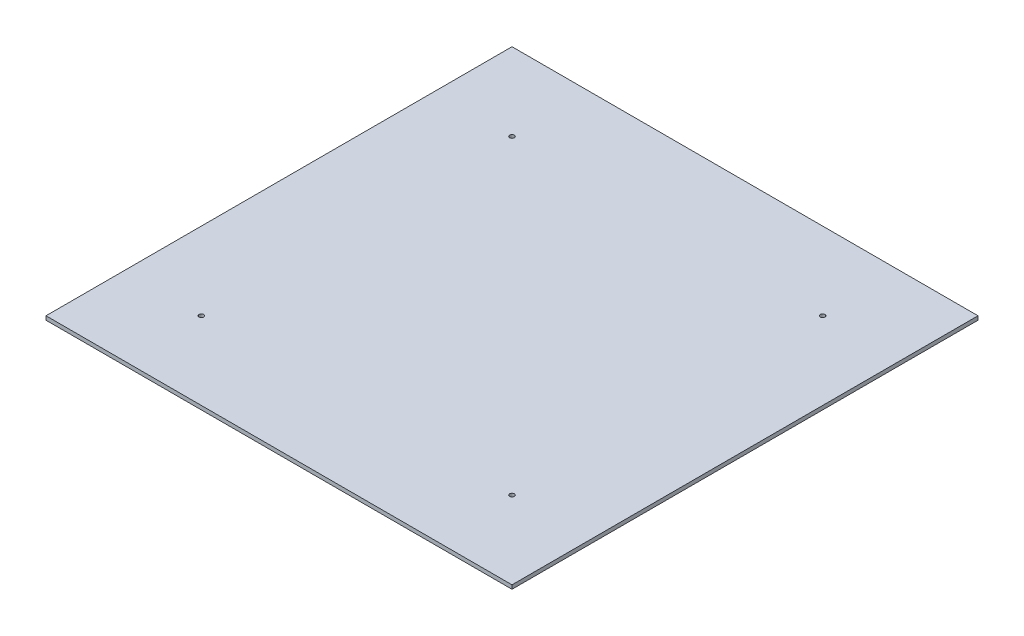
from build123d import *

# Parameters (mm, degrees)
SKETCH1_W           = 300
SKETCH1_H           = 300
SKETCH1_R           = 1.5
BOSS_EXTRUDE1_DEPTH = 2.5


with BuildPart() as part:
    # Sketch1 → Boss-Extrude1 (new body)
    with BuildSketch(Plane(origin=(0, 0, 0), x_dir=(1, 0, 0), z_dir=(0, 1, 0))):
        Rectangle(SKETCH1_W, SKETCH1_H)
        with Locations((-100, 100)):
            Circle(SKETCH1_R, mode=Mode.SUBTRACT)
        with Locations((100, 100)):
            Circle(SKETCH1_R, mode=Mode.SUBTRACT)
        with Locations((-100, -100)):
            Circle(SKETCH1_R, mode=Mode.SUBTRACT)
        with Locations((100, -100)):
            Circle(SKETCH1_R, mode=Mode.SUBTRACT)
    extrude(amount=BOSS_EXTRUDE1_DEPTH)


solid = part.part
